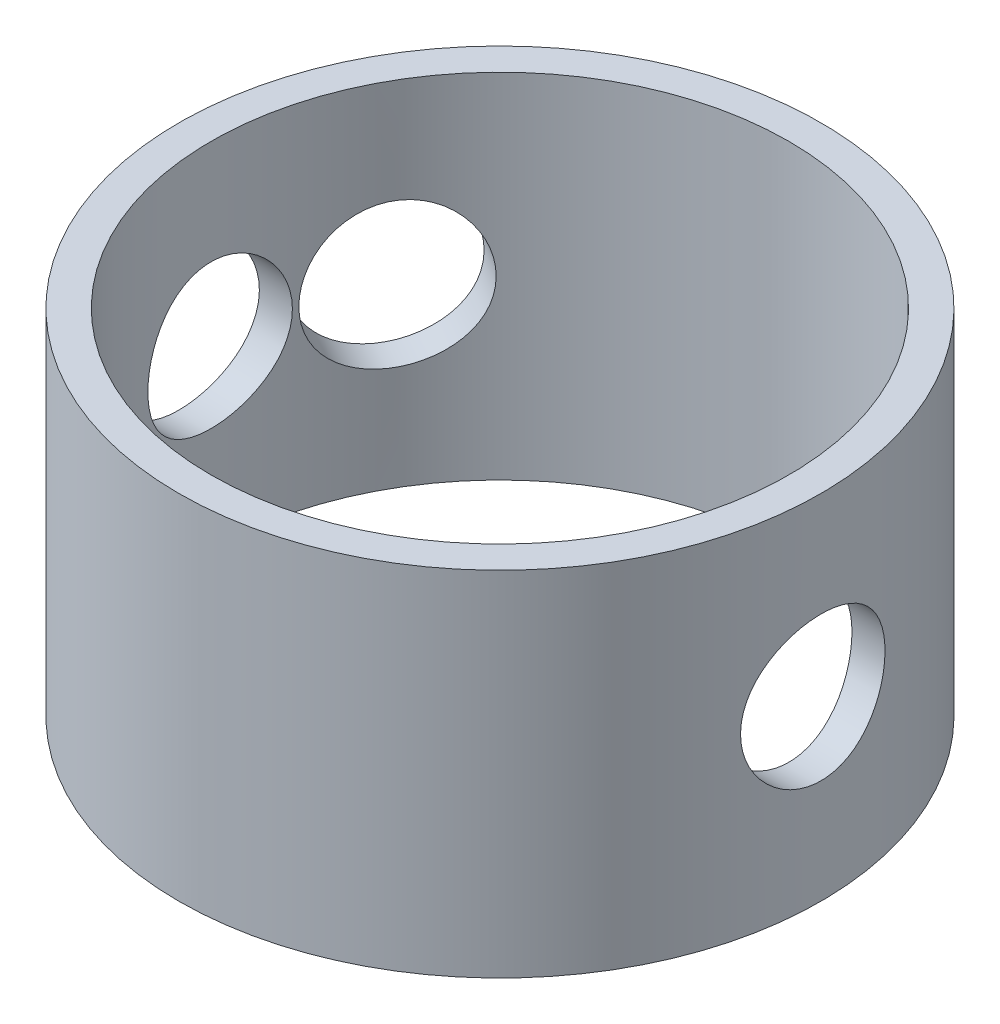
from build123d import *

# Parameters (mm, degrees)
ESBO_O1_R                  = 10
ESBO_O1_R_2                = 9
RESSALTO_EXTRUS_O1_DEPTH   = 5.5
CORTE_EXTRUS_O1_REACH      = 25.66
ESBO_O2_R                  = 2.25
ESBO_O3_R                  = 2.25
CORTE_EXTRUS_O2_DEPTH      = 11.0000001
CORTE_EXTRUS_O2_DEPTH_BACK = 11.0000001


with BuildPart() as part:
    # Esboço1 → Ressalto-extrusão1 (new body, symmetric)
    with BuildSketch(Plane(origin=(0, 0, 0), x_dir=(1, 0, 0), z_dir=(0, 1, 0))):
        Circle(ESBO_O1_R)
        Circle(ESBO_O1_R_2, mode=Mode.SUBTRACT)
    extrude(amount=RESSALTO_EXTRUS_O1_DEPTH, both=True)

    # Esboço2 → Corte-extrusão1 (cut, up to next)
    with BuildSketch(Plane(origin=(-8.660254038, 0, -5), x_dir=(-0.5, 0, 0.866025404), z_dir=(-0.866025404, 0, -0.5)), mode=Mode.PRIVATE) as corte_extrus_o1_sk1:
        Circle(ESBO_O2_R)
    corte_extrus_o1_tool1 = extrude(corte_extrus_o1_sk1.sketch, amount=-CORTE_EXTRUS_O1_REACH, mode=Mode.PRIVATE) & part.part
    add(corte_extrus_o1_tool1.solids().sort_by_distance((-8.660254, 0, -5))[0], mode=Mode.SUBTRACT)

    # Esboço3 → Corte-extrusão2 (cut, two sides)
    with BuildSketch(Plane(origin=(0, 0, 0), x_dir=(0, 0, -1), z_dir=(1, 0, 0))) as corte_extrus_o2_sk:
        Circle(ESBO_O3_R)
    extrude(amount=CORTE_EXTRUS_O2_DEPTH, mode=Mode.SUBTRACT)
    extrude(corte_extrus_o2_sk.sketch, amount=-CORTE_EXTRUS_O2_DEPTH_BACK, mode=Mode.SUBTRACT)


solid = part.part
